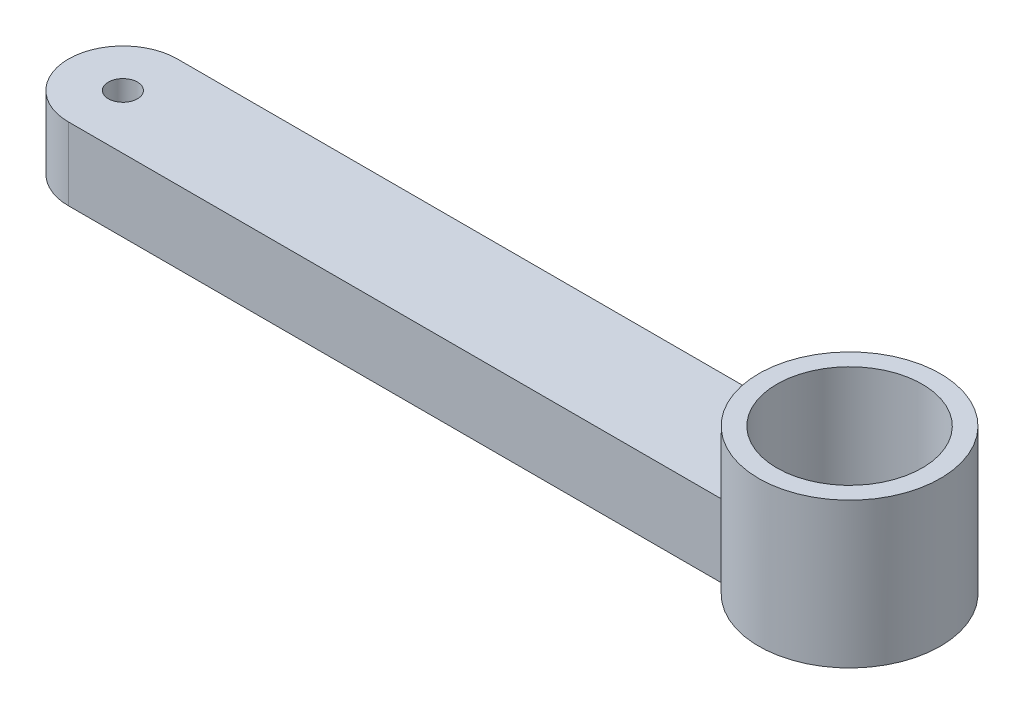
from build123d import *

# Parameters (mm, degrees)
SKETCH2_R           = 2
SKETCH2_R_2         = 2.5
BOSS_EXTRUDE1_DEPTH = 10
SKETCH3_R           = 12.5
BOSS_EXTRUDE3_DEPTH = 20
CUT_EXTRUDE1_REACH  = 22
SKETCH4_R           = 10


with BuildPart() as part:
    # Sketch2 → Boss-Extrude1 (new body)
    with BuildSketch(Plane(origin=(0, 0, 0), x_dir=(1, 0, 0), z_dir=(0, 1, 0))):
        with BuildLine():
            Line((0, 7.5), (100, 7.5))
            ThreePointArc((100, 7.5), (107.5, 0), (100, -7.5))
            Line((100, -7.5), (0, -7.5))
            ThreePointArc((0, -7.5), (-7.5, 0), (0, 7.5))
        make_face()
        Circle(SKETCH2_R, mode=Mode.SUBTRACT)
        with Locations((100, 0)):
            Circle(SKETCH2_R_2, mode=Mode.SUBTRACT)
    extrude(amount=BOSS_EXTRUDE1_DEPTH)

    # Sketch3 → Boss-Extrude3 (add)
    with BuildSketch(Plane(origin=(0, 0, 0), x_dir=(1, 0, 0), z_dir=(0, 1, 0))):
        with Locations((100, 0)):
            Circle(SKETCH3_R)
    extrude(amount=BOSS_EXTRUDE3_DEPTH)

    # Sketch4 → Cut-Extrude1 (cut, up to next)
    with BuildSketch(Plane(origin=(0, 20, 0), x_dir=(1, 0, 0), z_dir=(0, 1, 0)), mode=Mode.PRIVATE) as cut_extrude1_sk1:
        with Locations((100, 0)):
            Circle(SKETCH4_R)
    cut_extrude1_tool1 = extrude(cut_extrude1_sk1.sketch, amount=-CUT_EXTRUDE1_REACH, mode=Mode.PRIVATE) & part.part
    add(cut_extrude1_tool1.solids().sort_by_distance((100, 20, 0))[0], mode=Mode.SUBTRACT)


solid = part.part
